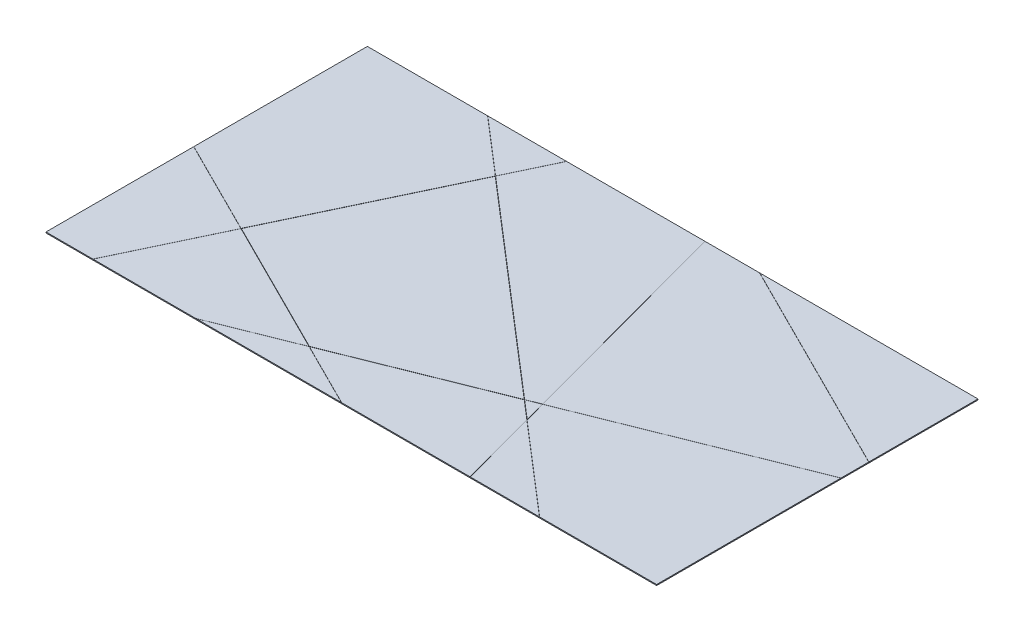
from build123d import *

# Parameters (mm, degrees)
BOSS_EXTRU_1_DEPTH    = 1.5
BOSS_EXTRU_1_2_DEPTH  = 1.5
BOSS_EXTRU_1_3_DEPTH  = 1.5
BOSS_EXTRU_1_4_DEPTH  = 1.5
BOSS_EXTRU_1_5_DEPTH  = 1.5
BOSS_EXTRU_1_6_DEPTH  = 1.5
BOSS_EXTRU_1_7_DEPTH  = 1.5
BOSS_EXTRU_1_8_DEPTH  = 1.5
BOSS_EXTRU_1_9_DEPTH  = 1.5
BOSS_EXTRU_1_10_DEPTH = 1.5
BOSS_EXTRU_1_11_DEPTH = 1.5
BOSS_EXTRU_1_12_DEPTH = 1.5
BOSS_EXTRU_1_13_DEPTH = 1.5


with BuildPart() as part:
    # Esquisse1 → Boss.-Extru.1 (new body)
    with BuildSketch(Plane(origin=(0, 0, 0), x_dir=(1, 0, 0), z_dir=(0, 1, 0))):
        Polygon((0, 500), (0, 230), (146.967396798, 156.516301601), (147.053079597, 156.697066999), (274.117042274, 424.764498808), (274.205876744, 424.951913301), (187, 500), align=None)
    extrude(amount=BOSS_EXTRU_1_DEPTH)


with BuildPart() as body_2:
    # Esquisse1 → Boss.-Extru.1 2 (new body)
    with BuildSketch(Plane(origin=(0, 0, 0), x_dir=(1, 0, 0), z_dir=(0, 1, 0))):
        Polygon((146.881713999, 156.335536203), (0, 229.776393202), (0, 0), (73, 0), (147.060638947, 156.246073729), align=None)
    extrude(amount=BOSS_EXTRU_1_2_DEPTH)


with BuildPart() as body_3:
    # Esquisse1 → Boss.-Extru.1 3 (new body)
    with BuildSketch(Plane(origin=(0, 0, 0), x_dir=(1, 0, 0), z_dir=(0, 1, 0))):
        Polygon((309.778669839, 500), (187.306610111, 500), (274.294711214, 425.139327794), align=None)
    extrude(amount=BOSS_EXTRU_1_3_DEPTH)


with BuildPart() as body_4:
    # Esquisse1 → Boss.-Extru.1 4 (new body)
    with BuildSketch(Plane(origin=(0, 0, 0), x_dir=(1, 0, 0), z_dir=(0, 1, 0))):
        Polygon((358.58437264, 50.484206882), (147.239563895, 156.156611255), (73.221330161, 0), (233, 0), (358.823662163, 50.364562121), align=None)
    extrude(amount=BOSS_EXTRU_1_4_DEPTH)


with BuildPart() as body_5:
    # Esquisse1 → Boss.-Extru.1 5 (new body)
    with BuildSketch(Plane(origin=(0, 0, 0), x_dir=(1, 0, 0), z_dir=(0, 1, 0))):
        Polygon((274.431450155, 424.49392404), (147.410929493, 156.518142051), (359.081122676, 50.68304546), (597.77664453, 146.227835937), align=None)
    extrude(amount=BOSS_EXTRU_1_5_DEPTH)


with BuildPart() as body_6:
    # Esquisse1 → Boss.-Extru.1 6 (new body)
    with BuildSketch(Plane(origin=(0, 0, 0), x_dir=(1, 0, 0), z_dir=(0, 1, 0))):
        Polygon((525, 500), (310, 500), (274.451915154, 425.00404041), (274.609119095, 424.868753026), (598.195189423, 146.395370643), (618.113419218, 154.368218553), (618.300375619, 154.443053263), align=None)
    extrude(amount=BOSS_EXTRU_1_6_DEPTH)


with BuildPart() as body_7:
    # Esquisse1 → Boss.-Extru.1 7 (new body)
    with BuildSketch(Plane(origin=(0, 0, 0), x_dir=(1, 0, 0), z_dir=(0, 1, 0))):
        Polygon((359.559701721, 50.443755937), (359.311326703, 50.344336649), (460, 0), (659.792838227, 0), (627.132357343, 120.964744015), (598.118358298, 145.933762127), align=None)
    extrude(amount=BOSS_EXTRU_1_7_DEPTH)


with BuildPart() as body_8:
    # Esquisse1 → Boss.-Extru.1 8 (new body)
    with BuildSketch(Plane(origin=(0, 0, 0), x_dir=(1, 0, 0), z_dir=(0, 1, 0))):
        Polygon((359.062951685, 50.24491736), (233.538192985, 0), (459.552786405, 0), align=None)
    extrude(amount=BOSS_EXTRU_1_8_DEPTH)


with BuildPart() as body_9:
    # Esquisse1 → Boss.-Extru.1 9 (new body)
    with BuildSketch(Plane(origin=(0, 0, 0), x_dir=(1, 0, 0), z_dir=(0, 1, 0))):
        Polygon((610, 500), (525.207161773, 500), (618.48733202, 154.517887973), (618.539824278, 154.323472201), (950, 287), (950, 330), align=None)
    extrude(amount=BOSS_EXTRU_1_9_DEPTH)


with BuildPart() as body_10:
    # Esquisse1 → Boss.-Extru.1 10 (new body)
    with BuildSketch(Plane(origin=(0, 0, 0), x_dir=(1, 0, 0), z_dir=(0, 1, 0))):
        Polygon((627.402225034, 120.732499876), (660, 0), (767.693389889, 0), (627.672092724, 120.500255736), align=None)
    extrude(amount=BOSS_EXTRU_1_10_DEPTH)


with BuildPart() as body_11:
    # Esquisse1 → Boss.-Extru.1 11 (new body)
    with BuildSketch(Plane(origin=(0, 0, 0), x_dir=(1, 0, 0), z_dir=(0, 1, 0))):
        Polygon((950, 500), (610.447213595, 500), (950, 330.223606798), align=None)
    extrude(amount=BOSS_EXTRU_1_11_DEPTH)


with BuildPart() as body_12:
    # Esquisse1 → Boss.-Extru.1 12 (new body)
    with BuildSketch(Plane(origin=(0, 0, 0), x_dir=(1, 0, 0), z_dir=(0, 1, 0))):
        Polygon((618.218403735, 153.979387009), (598.536903191, 146.101296833), (626.946741357, 121.652210631), align=None)
    extrude(amount=BOSS_EXTRU_1_12_DEPTH)


with BuildPart() as body_13:
    # Esquisse1 → Boss.-Extru.1 13 (new body)
    with BuildSketch(Plane(origin=(0, 0, 0), x_dir=(1, 0, 0), z_dir=(0, 1, 0))):
        Polygon((950, 286.784572682), (618.592316537, 154.129056429), (627.486476737, 121.187722352), (627.579284731, 120.843989044), (768, 0), (950, 0), align=None)
    extrude(amount=BOSS_EXTRU_1_13_DEPTH)


solid = Compound([part.part, body_2.part, body_3.part, body_4.part, body_5.part, body_6.part, body_7.part, body_8.part, body_9.part, body_10.part, body_11.part, body_12.part, body_13.part])
